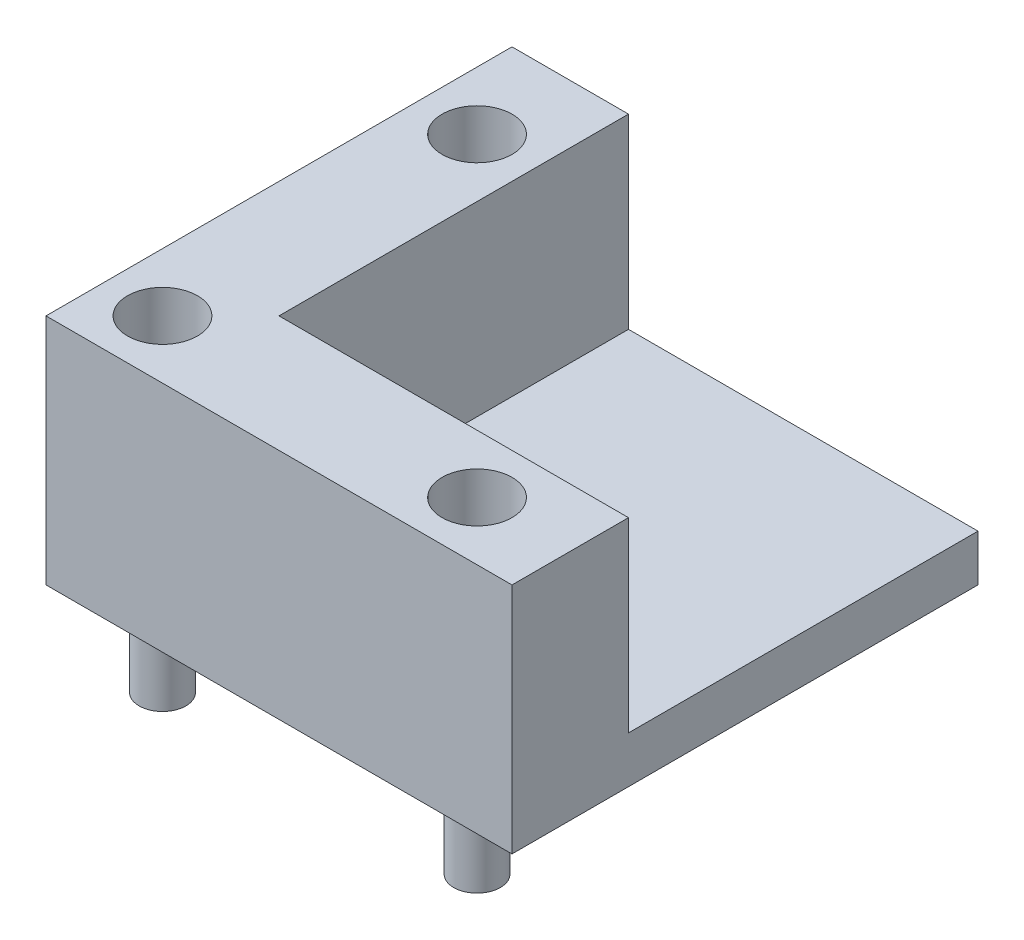
from build123d import *

# Parameters (mm, degrees)
SKETCH1_W           = 25.4
SKETCH1_H           = 25.4
BOSS_EXTRUDE1_DEPTH = 2.54
BOSS_EXTRUDE2_DEPTH = 10.16
SKETCH3_R           = 1.905
CUT_EXTRUDE1_DEPTH  = 6.35
SKETCH4_R           = 1.27
BOSS_EXTRUDE3_DEPTH = 5.08


with BuildPart() as part:
    # Sketch1 → Boss-Extrude1 (new body)
    with BuildSketch(Plane(origin=(0, 0, 0), x_dir=(1, 0, 0), z_dir=(0, 1, 0))):
        with Locations((12.7, 12.7)):
            Rectangle(SKETCH1_W, SKETCH1_H)
    extrude(amount=BOSS_EXTRUDE1_DEPTH)

    # Sketch2 → Boss-Extrude2 (add)
    with BuildSketch(Plane(origin=(0, 2.54, 0), x_dir=(1, 0, 0), z_dir=(0, 1, 0))):
        Polygon((0, 25.4), (0, 0), (25.4, 0), (25.4, 6.35), (6.35, 6.35), (6.35, 25.4), align=None)
    extrude(amount=BOSS_EXTRUDE2_DEPTH)

    # Sketch3 → Cut-Extrude1 (cut)
    with BuildSketch(Plane(origin=(0, 12.7, 0), x_dir=(1, 0, 0), z_dir=(0, 1, 0))):
        with Locations((3.175, 20.32)):
            Circle(SKETCH3_R)
        with Locations((3.175, 3.175)):
            Circle(SKETCH3_R)
        with Locations((20.32, 3.175)):
            Circle(SKETCH3_R)
    extrude(amount=-CUT_EXTRUDE1_DEPTH, mode=Mode.SUBTRACT)

    # Sketch4 → Boss-Extrude3 (add)
    with BuildSketch(Plane.XZ):
        with Locations((3.175, -3.175)):
            Circle(SKETCH4_R)
        with Locations((20.32, -3.175)):
            Circle(SKETCH4_R)
        with Locations((3.175, -20.32)):
            Circle(SKETCH4_R)
    extrude(amount=BOSS_EXTRUDE3_DEPTH)


solid = part.part
